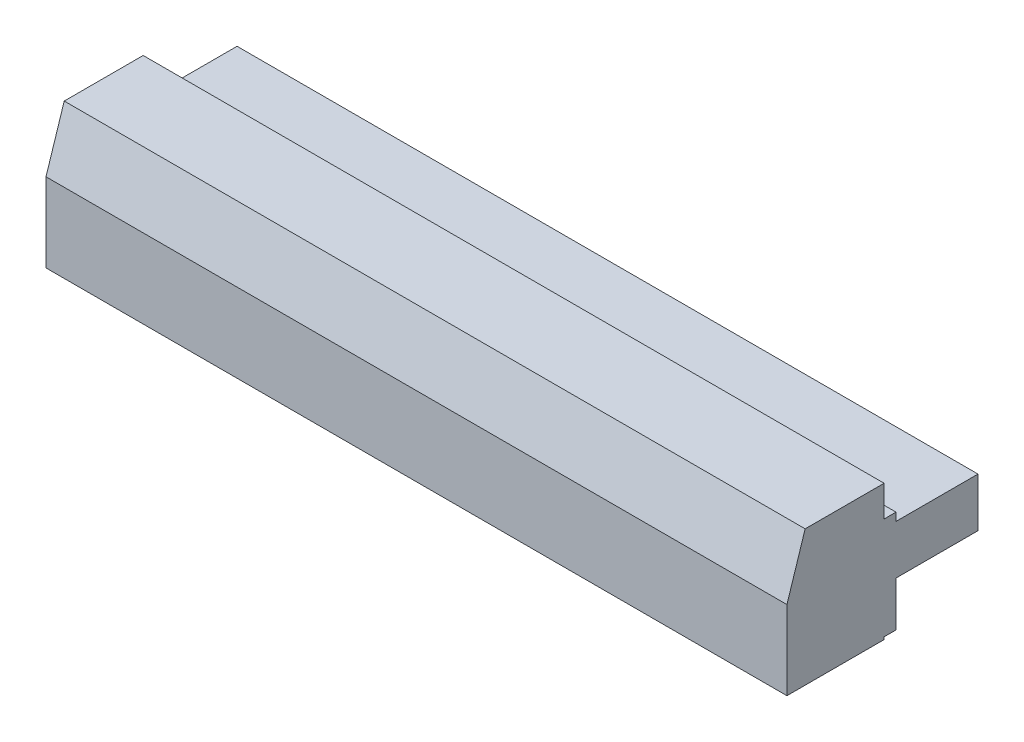
from build123d import *

# Parameters (mm, degrees)
BOSS_EXTRUDE1_DEPTH = 61


with BuildPart() as part:
    # Sketch1 → Boss-Extrude1 (new body)
    with BuildSketch(Plane(origin=(0, 0, 0), x_dir=(0, 0, -1), z_dir=(1, 0, 0))):
        Polygon((0, 0), (0, -0.2), (-8, -0.2), (-8, 6.3), (-6.5, 10.95), (0, 10.95), (0, 8.4), (0.98, 8.4), (0.98, 7.74), (7.73, 7.74), (7.73, 3.7), (0.98, 3.7), (0.98, 0), align=None)
    extrude(amount=BOSS_EXTRUDE1_DEPTH)


solid = part.part
